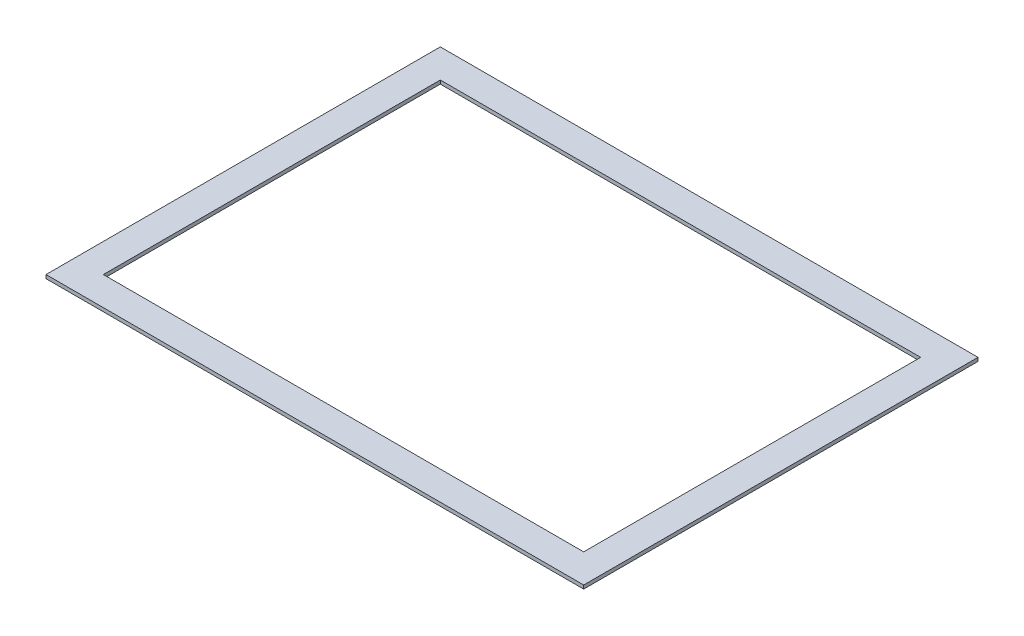
from build123d import *

# Parameters (mm, degrees)
SKETCH1_W           = 476.25
SKETCH1_H           = 349.25
SKETCH1_W_2         = 425.45
SKETCH1_H_2         = 298.45
BOSS_EXTRUDE1_DEPTH = 3.175


with BuildPart() as part:
    # Sketch1 → Boss-Extrude1 (new body)
    with BuildSketch(Plane(origin=(0, 0, 0), x_dir=(1, 0, 0), z_dir=(0, 1, 0))):
        Rectangle(SKETCH1_W, SKETCH1_H)
        Rectangle(SKETCH1_W_2, SKETCH1_H_2, mode=Mode.SUBTRACT)
    extrude(amount=BOSS_EXTRUDE1_DEPTH)


solid = part.part
